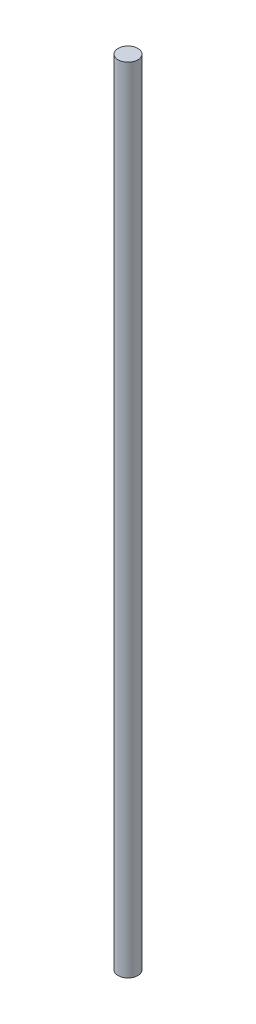
from build123d import *

# Parameters (mm, degrees)
SKETCH1_R           = 1.5
BOSS_EXTRUDE1_DEPTH = 120


with BuildPart() as part:
    # Sketch1 → Boss-Extrude1 (new body)
    with BuildSketch(Plane(origin=(0, 0, 0), x_dir=(1, 0, 0), z_dir=(0, 1, 0))):
        Circle(SKETCH1_R)
    extrude(amount=BOSS_EXTRUDE1_DEPTH)


solid = part.part
